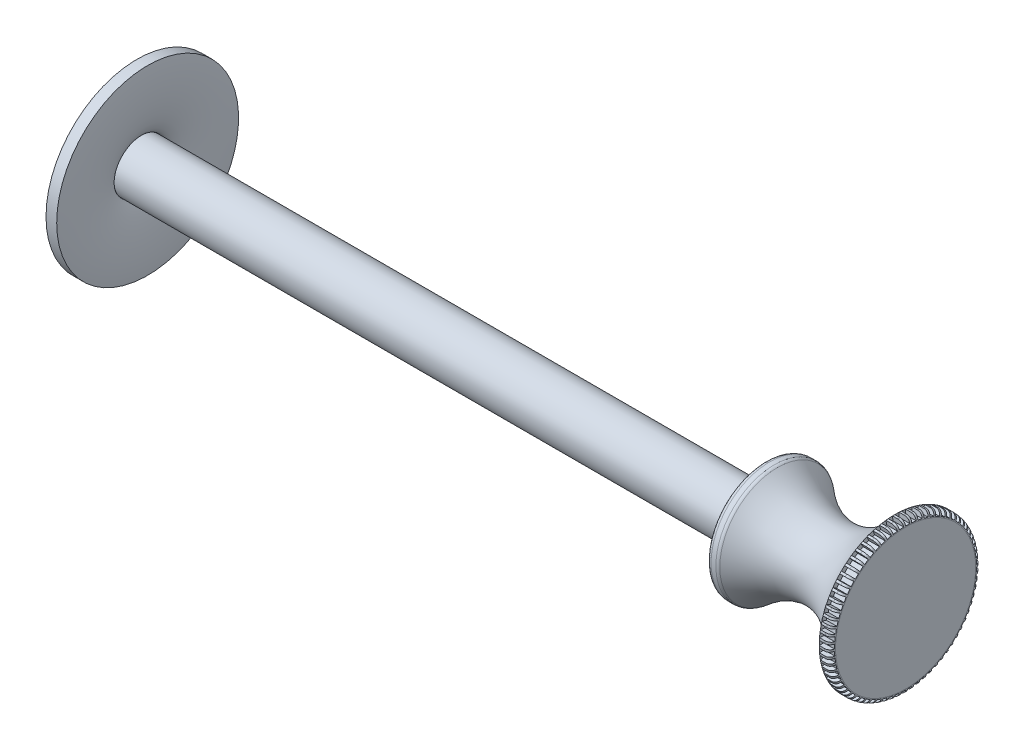
from build123d import *

# Parameters (mm, degrees)
ZAOBLIT2_R               = 0.5
ZAOBLIT3_R               = 0.4
SKICA2_W                 = 2
SKICA2_H                 = 0.4
ODEBRAT_VYSUNUT_M1_DEPTH = 0.5
KRUHOV_POLE1_COUNT       = 72


with BuildPart() as part:
    # Skica1 → Rotovat1 (revolve)
    with BuildSketch(Plane(origin=(0, 0, 0), x_dir=(1, 0, 0), z_dir=(0, 1, 0))):
        with BuildLine():
            Line((0, 0), (-13, 0))
            add(Edge.make_bspline(
                [(-13, 0), (-11.441154273, 0), (-12.220577137, 6)],
                knots=[0, 0, 0, 2.094395102, 2.094395102, 2.094395102], degree=2, weights=[1, 0.5, 1]))
            Line((-12.220577137, 6), (-13.21108805, 6))
            add(Edge.make_bspline(
                [(-14, 0.074893954), (-12.479128153, 0.074893954), (-13.21108805, 6)],
                knots=[0, 0, 0, 2.072906717, 2.072906717, 2.072906717], degree=2, weights=[1, 0.509275706, 1]))
            Line((-14, 0.074893954), (-14, -2.425106046))
            Line((-14, -2.425106046), (25.137573104, -2.425106046))
            Line((25.137573104, -2.425106046), (58, -2.425106046))
            Line((58, -2.425106046), (58, 4.574893954))
            Line((58, 4.574893954), (57, 4.574893954))
            add(Edge.make_bspline(
                [(46, 3), (51.856114119, -2.306152565), (57, 4.574893954)],
                knots=[0, 0, 0, 1, 1, 1], degree=2))
            Line((46, 3), (45, 3))
            Line((45, 3), (45, 0))
            Line((45, 0), (0, 0))
        make_face()
    revolve(axis=Axis((-14, 0, 2.425106046), (1, 0, 0)))

    # Zaoblit2
    zaoblit2_edges = [part.edges().sort_by_distance(p)[0] for p in [
        (58, 0, 9.425106046),
    ]]
    fillet(zaoblit2_edges, radius=ZAOBLIT2_R)

    # Zaoblit3
    zaoblit3_edges = [part.edges().sort_by_distance(p)[0] for p in [
        (45, 0, 7.850212091),
        (46, 0, 7.850212091),
    ]]
    fillet(zaoblit3_edges, radius=ZAOBLIT3_R)

    # Skica2 → Odebrat vysunutím1 (cut)
    with BuildSketch(Plane.XY.offset(9.5)):
        with Locations((58, 0.2)):
            Rectangle(SKICA2_W, SKICA2_H)
    odebrat_vysunut_m1 = extrude(amount=-ODEBRAT_VYSUNUT_M1_DEPTH, mode=Mode.SUBTRACT)

    # Kruhové pole1: Odebrat vysunutím1 ×72 about axis
    kruhov_pole1_axis = Axis((45, 0, 2.425106046), (-1, 0, 0))
    for i in range(1, KRUHOV_POLE1_COUNT):
        add(odebrat_vysunut_m1.rotate(kruhov_pole1_axis, i * 360 / KRUHOV_POLE1_COUNT), mode=Mode.SUBTRACT)


solid = part.part
